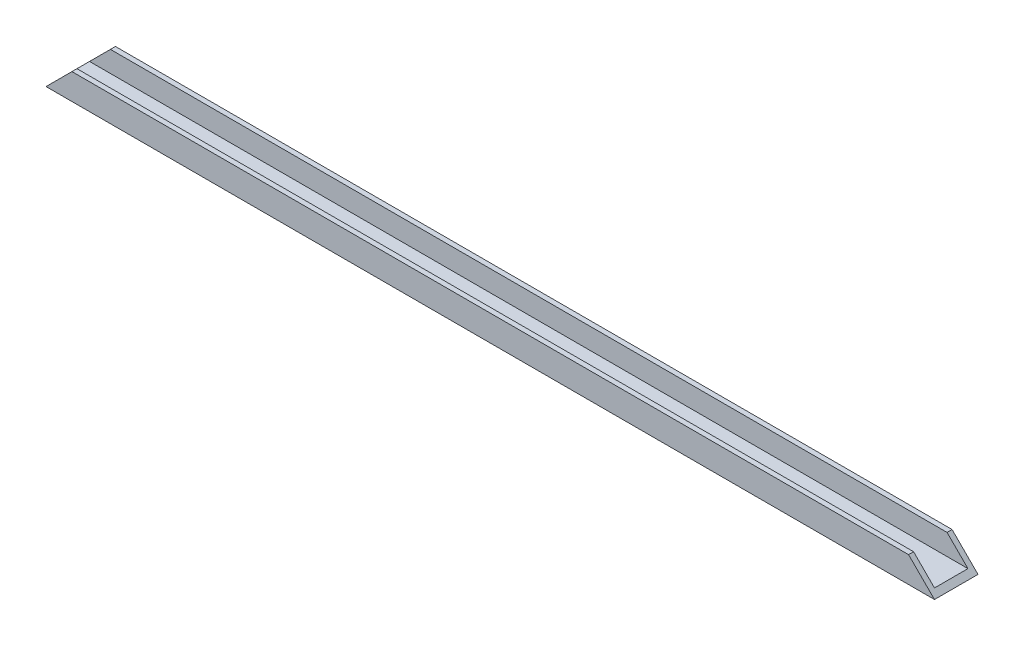
from build123d import *

# Parameters (mm, degrees)
BOSS_EXTRUDE1_DEPTH = 106.2
CUT_EXTRUDE1_DEPTH  = 11.4


with BuildPart() as part:
    # Sketch1 → Boss-Extrude1 (new body, symmetric)
    with BuildSketch(Plane(origin=(0, 0, 0), x_dir=(0, 0, -1), z_dir=(1, 0, 0))):
        Polygon((-4, 5), (-4, 0), (4, 0), (4, 5), (5.2, 5), (5.2, -1.2), (-5.2, -1.2), (-5.2, 5), align=None)
    extrude(amount=BOSS_EXTRUDE1_DEPTH, both=True)

    # Sketch3 → Cut-Extrude1 (cut, through all)
    with BuildSketch(Plane.XY.offset(5.2)):
        Polygon((-106.2, 5), (-106.2, -1.2), (-100, 5), align=None)
        Polygon((106.2, 5), (106.2, -1.2), (100, 5), align=None)
    extrude(amount=-CUT_EXTRUDE1_DEPTH, mode=Mode.SUBTRACT)


solid = part.part
